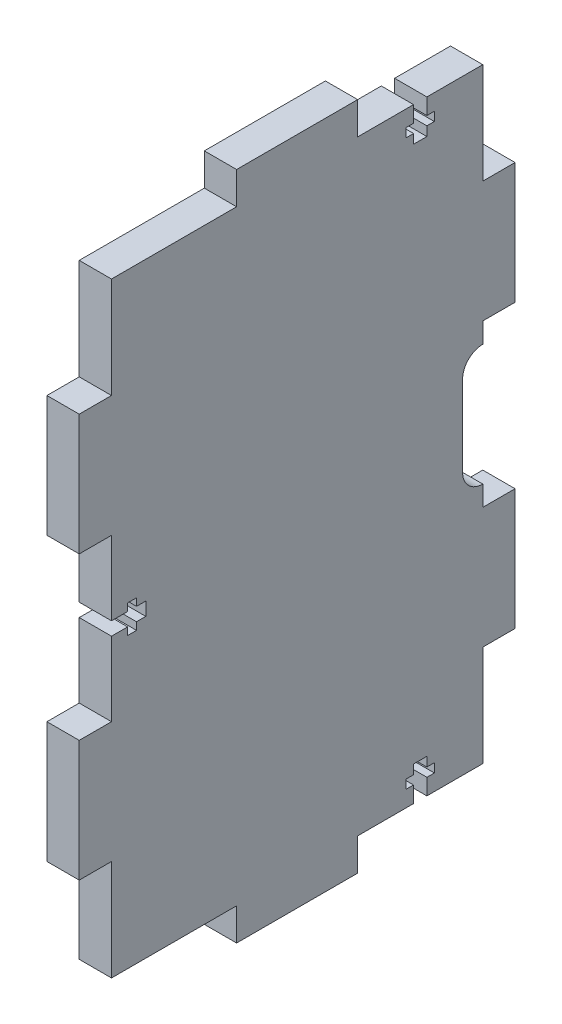
from build123d import *

# Parameters (mm, degrees)
SKETCH1_W           = 92
SKETCH1_H           = 150
BOSS_EXTRUDE1_DEPTH = 8
SKETCH2_W           = 30
SKETCH2_H           = 8
SKETCH2_W_2         = 8
SKETCH2_H_2         = 30
BOSS_EXTRUDE2_DEPTH = 8
CUT_EXTRUDE2_DEPTH  = 9


with BuildPart() as part:
    # Sketch1 → Boss-Extrude1 (new body)
    with BuildSketch(Plane(origin=(0, 0, 0), x_dir=(0, 0, -1), z_dir=(1, 0, 0))):
        with Locations((46, 75)):
            Rectangle(SKETCH1_W, SKETCH1_H)
    extrude(amount=BOSS_EXTRUDE1_DEPTH)

    # Sketch2 → Boss-Extrude2 (add)
    with BuildSketch(Plane.ZY):
        with Locations((-46, 154)):
            Rectangle(SKETCH2_W, SKETCH2_H)
        with Locations((-46, -4)):
            Rectangle(SKETCH2_W, SKETCH2_H)
        with Locations((4, 40)):
            Rectangle(SKETCH2_W_2, SKETCH2_H_2)
        with Locations((4, 110)):
            Rectangle(SKETCH2_W_2, SKETCH2_H_2)
        with Locations((-96, 40)):
            Rectangle(SKETCH2_W_2, SKETCH2_H_2)
        with Locations((-96, 110)):
            Rectangle(SKETCH2_W_2, SKETCH2_H_2)
    extrude(amount=-BOSS_EXTRUDE2_DEPTH)

    # Sketch4 → Cut-Extrude2 (cut, through all)
    with BuildSketch(Plane(origin=(8, 0, 0), x_dir=(0, 0, -1), z_dir=(1, 0, 0))):
        with BuildLine():
            Line((97, 85), (97, 65))
            ThreePointArc((97, 65), (92, 60), (87, 65))
            Line((87, 65), (87, 85))
            ThreePointArc((87, 85), (92, 90), (97, 85))
        make_face()
        Polygon((0, 76.65), (4, 76.65), (4, 78.5), (6.2, 78.5), (6.2, 76.65), (8.5, 76.65), (8.5, 73.35), (6.2, 73.35), (6.2, 71.5), (4, 71.5), (4, 73.35), (0, 73.35), align=None)
        Polygon((78.15, 0), (78.15, 4), (80, 4), (80, 6.2), (78.15, 6.2), (78.15, 8.5), (74.85, 8.5), (74.85, 6.2), (73, 6.2), (73, 4), (74.85, 4), (74.85, 0), align=None)
        Polygon((74.85, 150), (78.15, 150), (78.15, 146), (80, 146), (80, 143.8), (78.15, 143.8), (78.15, 141.5), (74.85, 141.5), (74.85, 143.8), (73, 143.8), (73, 146), (74.85, 146), align=None)
    extrude(amount=-CUT_EXTRUDE2_DEPTH, mode=Mode.SUBTRACT)


solid = part.part
